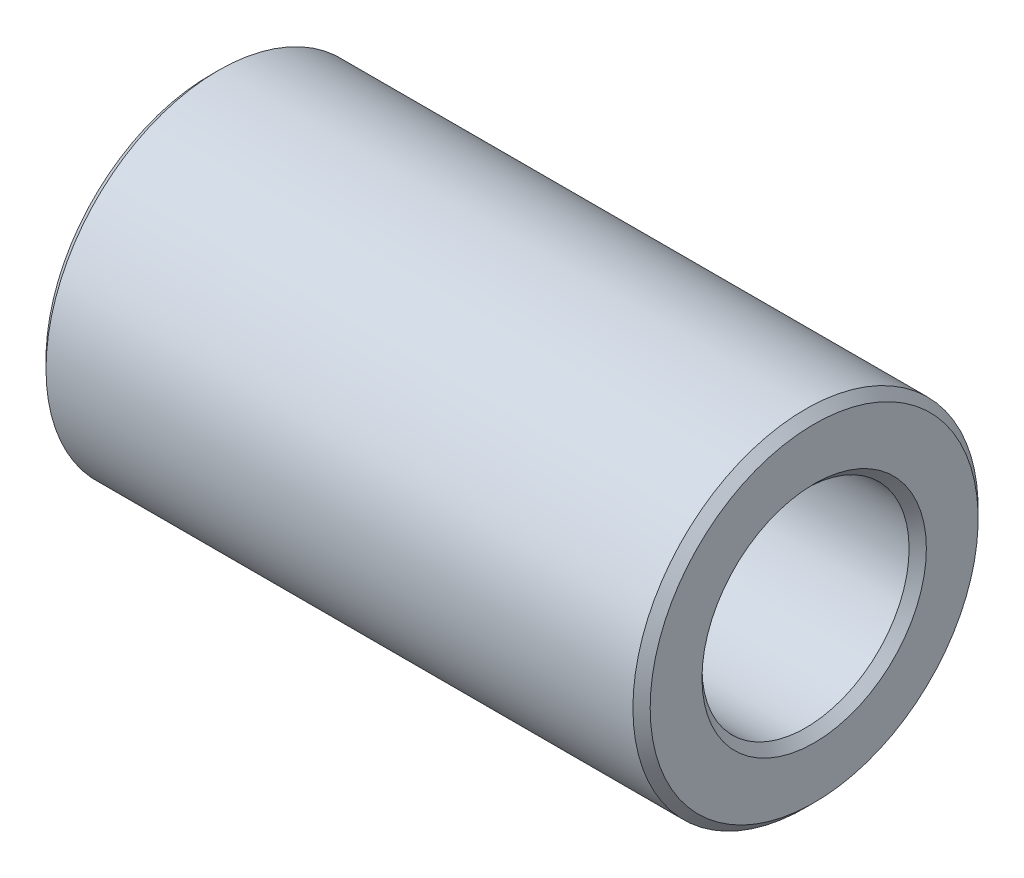
from build123d import *

# Parameters (mm, degrees)
SKETCH1_W     = 35
SKETCH1_H     = 4
CHAMFER1_SIZE = 0.5


with BuildPart() as part:
    # Sketch1 → Revolve1 (revolve)
    with BuildSketch(Plane.XY):
        with Locations((17.5, 8)):
            Rectangle(SKETCH1_W, SKETCH1_H)
    revolve(axis=Axis((-1000, 0, 0), (1, 0, 0)))

    # Chamfer1
    chamfer1_edges = [part.edges().sort_by_distance(p)[0] for p in [
        (0, -6, 0),
        (35, -6, 0),
        (35, -10, 0),
        (0, -10, 0),
    ]]
    chamfer(chamfer1_edges, length=CHAMFER1_SIZE)


solid = part.part
